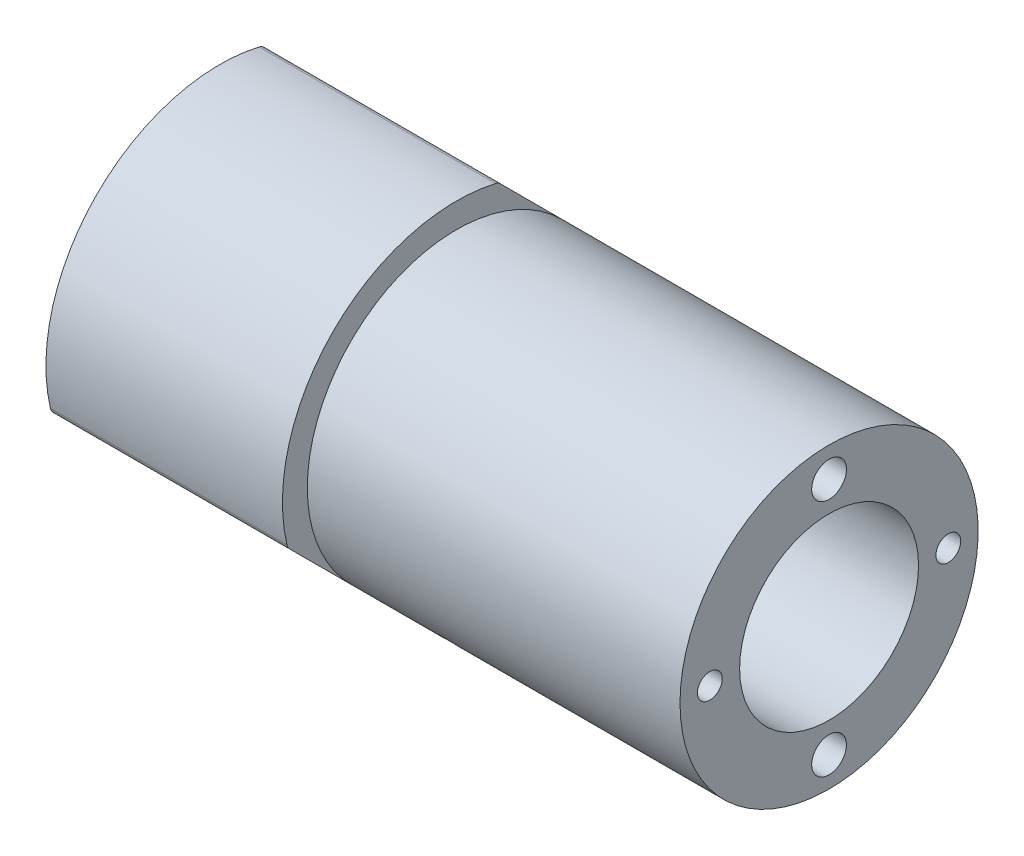
from build123d import *

# Parameters (mm, degrees)
CUT_EXTRUDE1_REACH          = 179.889
SKETCH8_R                   = 1.75
TAP_DRILL_FOR_M3_TAP2_D     = 2.5
TAP_DRILL_FOR_M3_TAP2_DEPTH = 6
TAP_DRILL_FOR_M3_TAP2_TIP   = 0.751075774
TAP_DRILL_FOR_M6_TAP1_D     = 5
TAP_DRILL_FOR_M6_TAP1_DEPTH = 10
TAP_DRILL_FOR_M6_TAP1_TIP   = 1.502151548
CUT_EXTRUDE2_REACH          = 179.889
FILLET1_R                   = 1
CUT_EXTRUDE3_REACH          = 335.718
SKETCH18_R                  = 1


with BuildPart() as part:
    # Sketch3 → Revolve1 (revolve)
    with BuildSketch(Plane.XY):
        Polygon((208.551545348, -139.573704322), (250.685153788, -139.573704322), (259.301545348, -139.573704322), (259.301545348, -133.573704322), (238.427343436, -133.573704322), (221.801545348, -133.573704322), (221.801545348, -131.073704322), (198.001545348, -131.073704322), (198.001545348, -133.573704322), (198.001545348, -140.556086521), (198.001545348, -145.198704322), (205.151545348, -145.198704322), (205.151545348, -140.573704322), (208.551545348, -140.573704322), align=None)
    revolve(axis=Axis((227.370475166, -148.573704322, 0), (1, 0, 0)))

    # Sketch8 → Cut-Extrude1 (cut, up to next)
    with BuildSketch(Plane(origin=(259.301545348, 0, 0), x_dir=(0, 0, -1), z_dir=(1, 0, 0)), mode=Mode.PRIVATE) as cut_extrude1_sk1:
        with Locations((0, -136.573704322)):
            Circle(SKETCH8_R)
    cut_extrude1_tool1 = extrude(cut_extrude1_sk1.sketch, amount=-CUT_EXTRUDE1_REACH, mode=Mode.PRIVATE) & part.part
    # Sketch8 → Cut-Extrude1 (cut, up to next)
    with BuildSketch(Plane(origin=(259.301545348, 0, 0), x_dir=(0, 0, -1), z_dir=(1, 0, 0)), mode=Mode.PRIVATE) as cut_extrude1_sk2:
        with Locations((0, -160.573704322)):
            Circle(SKETCH8_R)
    cut_extrude1_tool2 = extrude(cut_extrude1_sk2.sketch, amount=-CUT_EXTRUDE1_REACH, mode=Mode.PRIVATE) & part.part
    add(cut_extrude1_tool1.solids().sort_by_distance((259.301545, -136.573704, 0))[0], mode=Mode.SUBTRACT)
    add(cut_extrude1_tool2.solids().sort_by_distance((259.301545, -160.573704, 0))[0], mode=Mode.SUBTRACT)

    # Tap Drill for M3 Tap2
    with Locations(Plane(origin=(259.301545348, 0, 0), x_dir=(0, 0, -1), z_dir=(1, 0, 0))):
        with Locations((-12, -148.573704322), (12, -148.573704322)):
            Hole(TAP_DRILL_FOR_M3_TAP2_D / 2, depth=TAP_DRILL_FOR_M3_TAP2_DEPTH)
            with Locations((0, 0, -(TAP_DRILL_FOR_M3_TAP2_DEPTH + TAP_DRILL_FOR_M3_TAP2_TIP / 2))):  # 118° drill point
                Cone(0, TAP_DRILL_FOR_M3_TAP2_D / 2, TAP_DRILL_FOR_M3_TAP2_TIP, mode=Mode.SUBTRACT)

    # Tap Drill for M6 Tap1
    with Locations(Plane.ZY.offset(-198.001545348)):
        with Locations((12, -148.573704322), (-12, -148.573704322)):
            Hole(TAP_DRILL_FOR_M6_TAP1_D / 2, depth=TAP_DRILL_FOR_M6_TAP1_DEPTH)
            with Locations((0, 0, -(TAP_DRILL_FOR_M6_TAP1_DEPTH + TAP_DRILL_FOR_M6_TAP1_TIP / 2))):  # 118° drill point
                Cone(0, TAP_DRILL_FOR_M6_TAP1_D / 2, TAP_DRILL_FOR_M6_TAP1_TIP, mode=Mode.SUBTRACT)

    # Sketch16 → Cut-Extrude2 (cut, up to next)
    with BuildSketch(Plane.ZY.offset(-198.001545348), mode=Mode.PRIVATE) as cut_extrude2_sk1:
        Polygon((-16.98037611, -144.340876996), (-4.232827326, -131.593328212), (-6.354147669, -129.472007869), (-19.101696453, -142.219556653), align=None)
    cut_extrude2_tool1 = extrude(cut_extrude2_sk1.sketch, amount=-CUT_EXTRUDE2_REACH, mode=Mode.PRIVATE) & part.part
    # Sketch16 → Cut-Extrude2 (cut, up to next)
    with BuildSketch(Plane.ZY.offset(-198.001545348), mode=Mode.PRIVATE) as cut_extrude2_sk2:
        Polygon((4.232827326, -165.554080432), (6.354147669, -167.675400776), (19.101696453, -154.927851992), (16.98037611, -152.806531648), align=None)
    cut_extrude2_tool2 = extrude(cut_extrude2_sk2.sketch, amount=-CUT_EXTRUDE2_REACH, mode=Mode.PRIVATE) & part.part
    add(cut_extrude2_tool1.solids().sort_by_distance((198.001545, -136.906442, -11.667262))[0], mode=Mode.SUBTRACT)
    add(cut_extrude2_tool2.solids().sort_by_distance((198.001545, -160.240966, 11.667262))[0], mode=Mode.SUBTRACT)

    # Fillet1
    fillet1_edges = [part.edges().sort_by_distance(p)[0] for p in [
        (209.901545348, -165.554080432, 4.232827326),
        (209.901545348, -152.806531648, 16.98037611),
        (209.901545348, -144.340876996, -16.98037611),
        (209.901545348, -131.593328212, -4.232827326),
    ]]
    fillet(fillet1_edges, radius=FILLET1_R)

    # Sketch18 → Cut-Extrude3 (cut, up to next)
    with BuildSketch(Plane(origin=(0, -289.84438159, -120.057473832), x_dir=(1, 0, 0), z_dir=(0, 0.7071067811865441, -0.7071067811865509)), mode=Mode.PRIVATE) as cut_extrude3_sk1:
        with Locations((231.801545348, -184.786907758)):
            Circle(SKETCH18_R)
    cut_extrude3_tool1 = extrude(cut_extrude3_sk1.sketch, amount=CUT_EXTRUDE3_REACH, mode=Mode.PRIVATE) & part.part
    add(cut_extrude3_tool1.solids().sort_by_distance((231.801545, -159.180306, 10.606602))[0], mode=Mode.SUBTRACT)


solid = part.part
